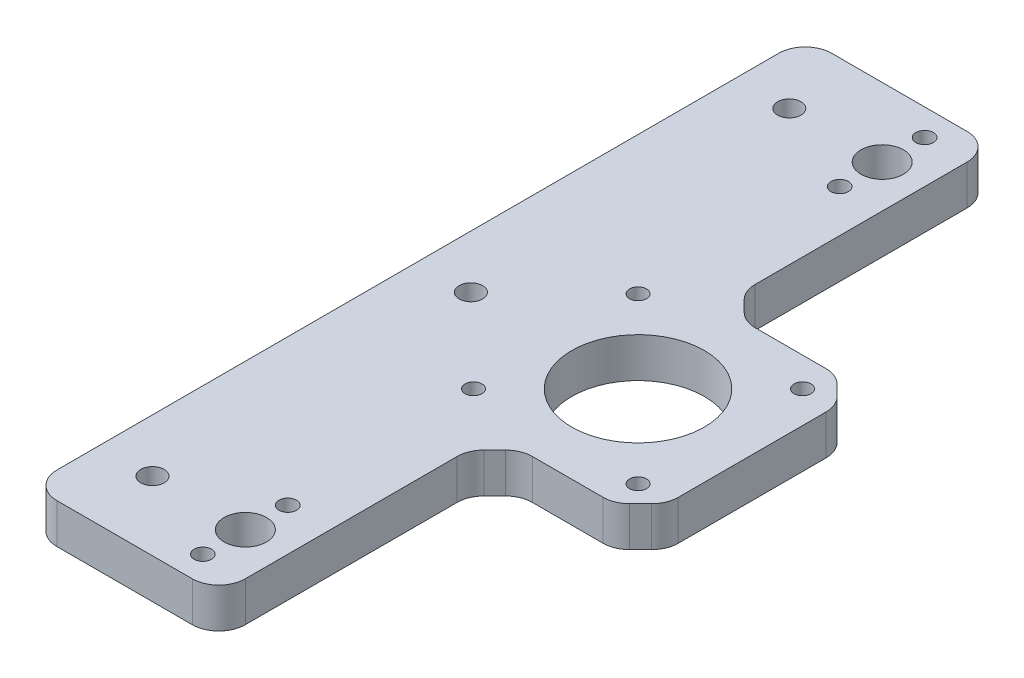
from build123d import *

# Parameters (mm, degrees)
SKETCH1_R           = 1.65
SKETCH1_R_2         = 1.6
SKETCH1_R_3         = 12.5
SKETCH1_R_4         = 2.2
SKETCH1_R_5         = 4
BOSS_EXTRUDE1_DEPTH = 7.5


with BuildPart() as part:
    # Sketch1 → Boss-Extrude1 (new body)
    with BuildSketch(Plane(origin=(0, 3.75, 0), x_dir=(1, 0, 0), z_dir=(0, 1, 0))):
        with BuildLine():
            Line((34.035533906, 17.464466094), (31.964466094, 19.535533906))
            ThreePointArc((31.964466094, 19.535533906), (30.34234935, 20.619397663), (28.428932188, 21))
            Line((28.428932188, 21), (15.071067812, 21))
            ThreePointArc((15.071067812, 21), (13.15765065, 21.380602337), (11.535533906, 22.464466094))
            Line((11.535533906, 22.464466094), (9.464466094, 24.535533906))
            ThreePointArc((9.464466094, 24.535533906), (8.380602337, 26.15765065), (8, 28.071067812))
            Line((8, 28.071067812), (8, 68))
            ThreePointArc((8, 68), (6.535533906, 71.535533906), (3, 73))
            Line((3, 73), (-22.5, 73))
            ThreePointArc((-22.5, 73), (-26.035533906, 71.535533906), (-27.5, 68))
            Line((-27.5, 68), (-27.5, -68))
            ThreePointArc((-27.5, -68), (-26.035533906, -71.535533906), (-22.5, -73))
            Line((-22.5, -73), (3, -73))
            ThreePointArc((3, -73), (6.535533906, -71.535533906), (8, -68))
            Line((8, -68), (8, -28.071067812))
            ThreePointArc((8, -28.071067812), (8.380602337, -26.15765065), (9.464466094, -24.535533906))
            Line((9.464466094, -24.535533906), (11.535533906, -22.464466094))
            ThreePointArc((11.535533906, -22.464466094), (13.15765065, -21.380602337), (15.071067812, -21))
            Line((15.071067812, -21), (28.428932188, -21))
            ThreePointArc((28.428932188, -21), (30.34234935, -20.619397663), (31.964466094, -19.535533906))
            Line((31.964466094, -19.535533906), (34.035533906, -17.464466094))
            ThreePointArc((34.035533906, -17.464466094), (35.119397663, -15.84234935), (35.5, -13.928932188))
            Line((35.5, -13.928932188), (35.5, 13.928932188))
            ThreePointArc((35.5, 13.928932188), (35.119397663, 15.84234935), (34.035533906, 17.464466094))
        make_face()
        with Locations((0, -68)):
            Circle(SKETCH1_R, mode=Mode.SUBTRACT)
        with Locations((0, -52)):
            Circle(SKETCH1_R, mode=Mode.SUBTRACT)
        with Locations((0, 68)):
            Circle(SKETCH1_R, mode=Mode.SUBTRACT)
        with Locations((0, 52)):
            Circle(SKETCH1_R, mode=Mode.SUBTRACT)
        with Locations((29.5, 15.5)):
            Circle(SKETCH1_R_2, mode=Mode.SUBTRACT)
        with Locations((-1.5, 15.5)):
            Circle(SKETCH1_R_2, mode=Mode.SUBTRACT)
        with Locations((-1.5, -15.5)):
            Circle(SKETCH1_R_2, mode=Mode.SUBTRACT)
        with Locations((29.5, -15.5)):
            Circle(SKETCH1_R_2, mode=Mode.SUBTRACT)
        with Locations((14, 0)):
            Circle(SKETCH1_R_3, mode=Mode.SUBTRACT)
        with Locations((-17.5, 0)):
            Circle(SKETCH1_R_4, mode=Mode.SUBTRACT)
        with Locations((0, -60)):
            Circle(SKETCH1_R_5, mode=Mode.SUBTRACT)
        with Locations((0, 60)):
            Circle(SKETCH1_R_5, mode=Mode.SUBTRACT)
        with Locations((-17.5, 60)):
            Circle(SKETCH1_R_4, mode=Mode.SUBTRACT)
        with Locations((-17.5, -60)):
            Circle(SKETCH1_R_4, mode=Mode.SUBTRACT)
    extrude(amount=-BOSS_EXTRUDE1_DEPTH)


solid = part.part
